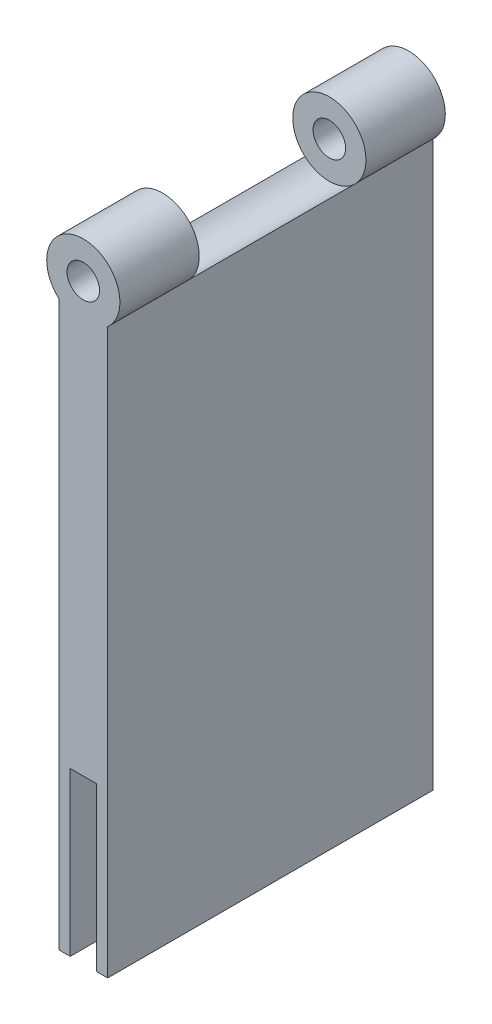
from build123d import *

# Parameters (mm, degrees)
SKETCH1_W               = 6
SKETCH1_H               = 40
BOSS_EXTRUDE1_DEPTH     = 60
SKETCH2_W               = 3.2
SKETCH2_H               = 40
CUT_EXTRUDE2_DEPTH      = 20
SKETCH3_R               = 2
CUT_EXTRUDE3_DEPTH      = 1
CUT_EXTRUDE3_DEPTH_BACK = 41
SKETCH4_R               = 4.5
BOSS_EXTRUDE2_DEPTH     = 40
SKETCH6_R               = 2
CUT_EXTRUDE4_DEPTH      = 40
SKETCH7_W               = 20.491200394
SKETCH7_H               = 6.65
CUT_EXTRUDE5_DEPTH      = 2.5
CUT_EXTRUDE5_DEPTH_BACK = 8.5
SKETCH8_R               = 4.5
CUT_EXTRUDE6_DEPTH      = 20.4912
SKETCH9_W               = 1.395608407
SKETCH9_H               = 40
SKETCH9_W_2             = 1.404391593
BOSS_EXTRUDE3_DEPTH     = 15
SKETCH10_W              = 3.2
SKETCH10_H              = 40
BOSS_EXTRUDE4_DEPTH     = 15


with BuildPart() as part:
    # Sketch1 → Boss-Extrude1 (new body)
    with BuildSketch(Plane(origin=(0, 0, 0), x_dir=(1, 0, 0), z_dir=(0, 1, 0))):
        with Locations((-39.19123506, 9.482071713)):
            Rectangle(SKETCH1_W, SKETCH1_H)
    extrude(amount=BOSS_EXTRUDE1_DEPTH)

    # Sketch2 → Cut-Extrude2 (cut)
    with BuildSketch(Plane.XZ):
        with Locations((-39.195626653, -9.482071713)):
            Rectangle(SKETCH2_W, SKETCH2_H)
    extrude(amount=-CUT_EXTRUDE2_DEPTH, mode=Mode.SUBTRACT)

    # Sketch3 → Cut-Extrude3 (cut, two sides)
    with BuildSketch(Plane.XY.offset(10.517928287)) as cut_extrude3_sk:
        with Locations((-39.19123506, 57.687817086)):
            Circle(SKETCH3_R)
    extrude(amount=CUT_EXTRUDE3_DEPTH, mode=Mode.SUBTRACT)
    extrude(cut_extrude3_sk.sketch, amount=-CUT_EXTRUDE3_DEPTH_BACK, mode=Mode.SUBTRACT)

    # Sketch4 → Boss-Extrude2 (add)
    with BuildSketch(Plane.XY.offset(10.517928287)):
        with Locations((-39.19123506, 57.687817086)):
            Circle(SKETCH4_R)
    extrude(amount=-BOSS_EXTRUDE2_DEPTH)

    # Sketch6 → Cut-Extrude4 (cut)
    with BuildSketch(Plane.XY.offset(10.517928287)):
        with Locations((-39.19123506, 57.687817086)):
            Circle(SKETCH6_R)
    extrude(amount=-CUT_EXTRUDE4_DEPTH, mode=Mode.SUBTRACT)

    # Sketch7 → Cut-Extrude5 (cut, two sides)
    with BuildSketch(Plane(origin=(-36.19123506, 0, 0), x_dir=(0, 0, -1), z_dir=(1, 0, 0))) as cut_extrude5_sk:
        with Locations((9.482071713, 58.362817086)):
            Rectangle(SKETCH7_W, SKETCH7_H)
    extrude(amount=CUT_EXTRUDE5_DEPTH, mode=Mode.SUBTRACT)
    extrude(cut_extrude5_sk.sketch, amount=-CUT_EXTRUDE5_DEPTH_BACK, mode=Mode.SUBTRACT)

    # Sketch8 → Cut-Extrude6 (cut)
    with BuildSketch(Plane(origin=(0, 0, 0.763528484), x_dir=(-1, 0, 0), z_dir=(0, 0, -1))):
        with Locations((39.19123506, 57.687817086)):
            Circle(SKETCH8_R)
    extrude(amount=CUT_EXTRUDE6_DEPTH, mode=Mode.SUBTRACT)

    # Sketch9 → Boss-Extrude3 (add)
    with BuildSketch(Plane.XZ):
        with Locations((-41.493430856, -9.482071713)):
            Rectangle(SKETCH9_W, SKETCH9_H)
        with Locations((-36.893430857, -9.482071713)):
            Rectangle(SKETCH9_W_2, SKETCH9_H)
    extrude(amount=BOSS_EXTRUDE3_DEPTH)

    # Sketch10 → Boss-Extrude4 (add)
    with BuildSketch(Plane.XZ.offset(-20)):
        with Locations((-39.195626653, -9.482071713)):
            Rectangle(SKETCH10_W, SKETCH10_H)
    extrude(amount=BOSS_EXTRUDE4_DEPTH)


solid = part.part
